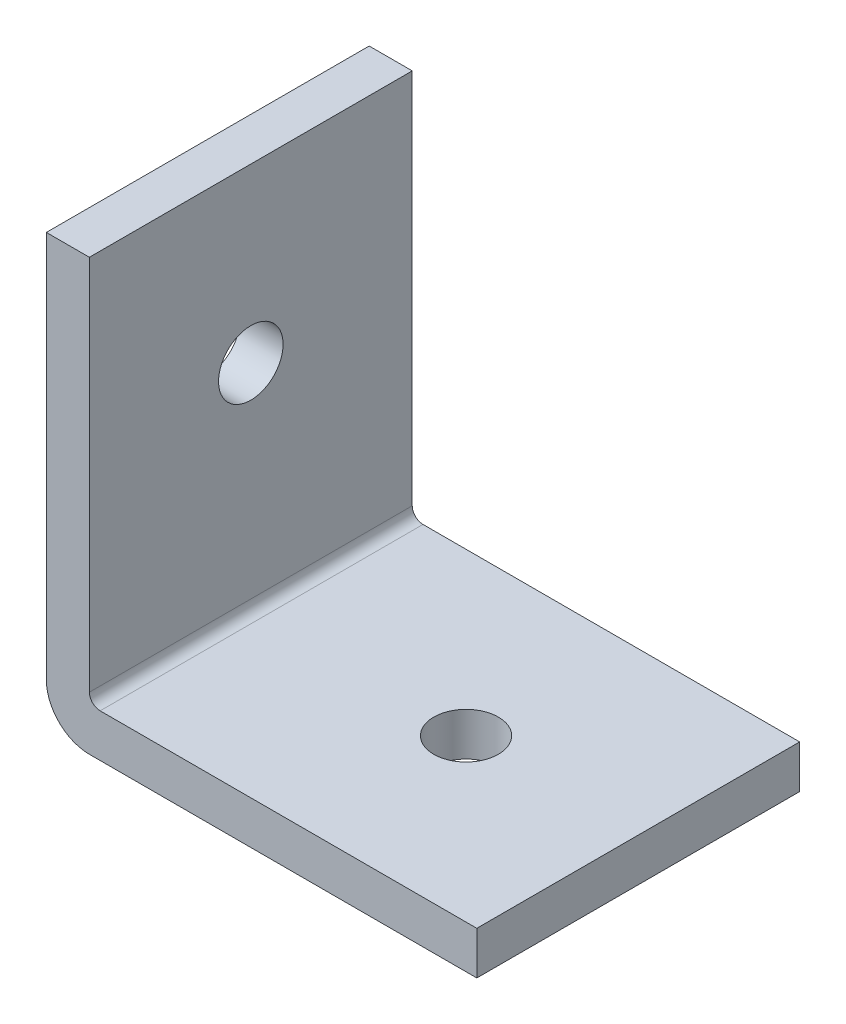
from build123d import *

# Parameters (mm, degrees)
BOSS_EXTRUDE1_DEPTH = 15
SKETCH3_R           = 1.5
CUT_EXTRUDE2_DEPTH  = 3
SKETCH4_R           = 1.5
CUT_EXTRUDE3_DEPTH  = 3


with BuildPart() as part:
    # Sketch1 → Boss-Extrude1 (new body)
    with BuildSketch(Plane.XY):
        with BuildLine():
            Line((0, 2), (0, 20))
            Line((0, 20), (2, 20))
            Line((2, 20), (2, 2.5))
            ThreePointArc((2, 2.5), (2.146446609, 2.146446609), (2.5, 2))
            Line((2.5, 2), (20, 2))
            Line((20, 2), (20, 0))
            Line((20, 0), (2, 0))
            ThreePointArc((2, 0), (0.585786438, 0.585786438), (0, 2))
        make_face()
    extrude(amount=BOSS_EXTRUDE1_DEPTH)

    # Sketch3 → Cut-Extrude2 (cut, through all)
    with BuildSketch(Plane(origin=(0, 2, 0), x_dir=(1, 0, 0), z_dir=(0, 1, 0))):
        with Locations((12, -7.5)):
            Circle(SKETCH3_R)
    extrude(amount=-CUT_EXTRUDE2_DEPTH, mode=Mode.SUBTRACT)

    # Sketch4 → Cut-Extrude3 (cut, through all)
    with BuildSketch(Plane(origin=(2, 0, 0), x_dir=(0, 0, -1), z_dir=(1, 0, 0))):
        with Locations((-7.5, 12)):
            Circle(SKETCH4_R)
    extrude(amount=-CUT_EXTRUDE3_DEPTH, mode=Mode.SUBTRACT)


solid = part.part
